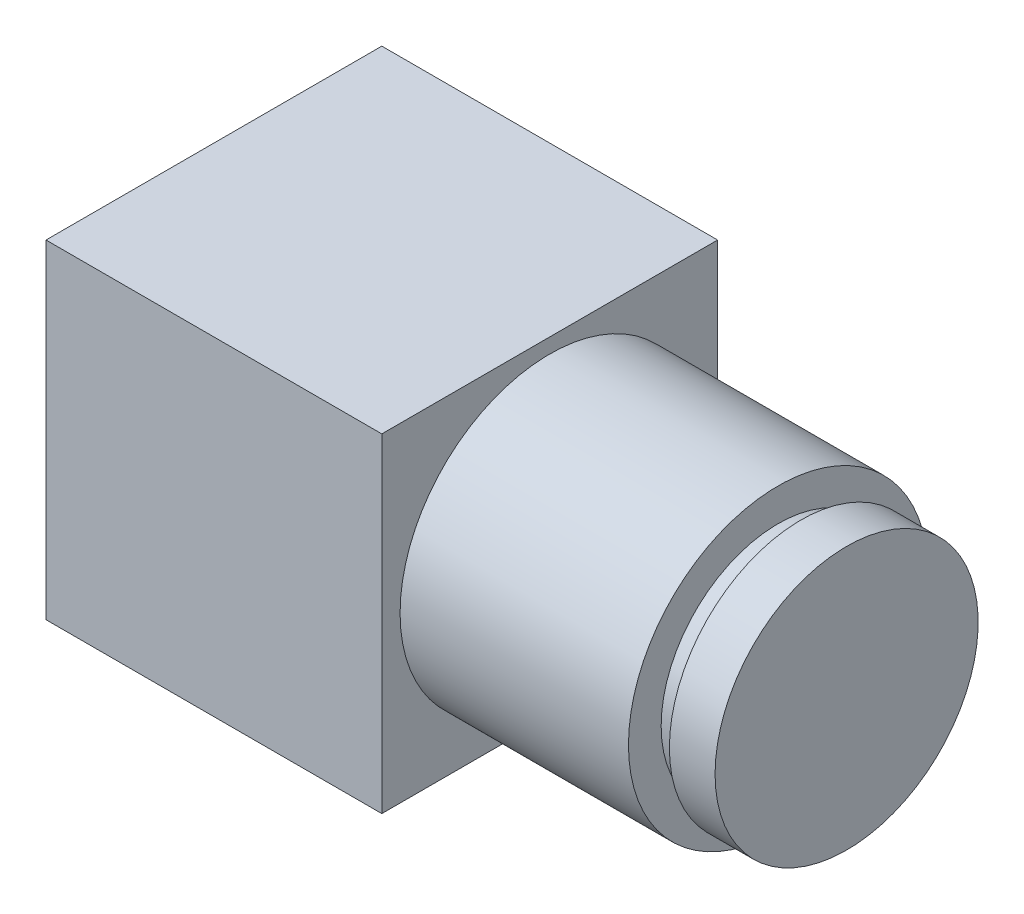
from build123d import *

# Parameters (mm, degrees)
SKETCH1_W           = 11.6713
SKETCH1_H           = 11.43
EXTRUDE1_DEPTH      = 5.83565
EXTRUDE1_DEPTH_BACK = 5.83565
SKETCH2_R           = 5.20065
EXTRUDE2_DEPTH      = 7.9375


with BuildPart() as part:
    # Sketch1 → Extrude1 (new body, two sides)
    with BuildSketch(Plane.XY) as extrude1_sk:
        with Locations((5.83565, 0)):
            Rectangle(SKETCH1_W, SKETCH1_H)
    extrude(amount=EXTRUDE1_DEPTH)
    extrude(extrude1_sk.sketch, amount=-EXTRUDE1_DEPTH_BACK)

    # Sketch2 → Extrude2 (add)
    with BuildSketch(Plane(origin=(11.6713, 0, 0), x_dir=(0, 0, -1), z_dir=(1, 0, 0))):
        Circle(SKETCH2_R)
    extrude(amount=EXTRUDE2_DEPTH)

    # Sketch3 → Revolve1 (revolve)
    with BuildSketch(Plane.XY):
        Polygon((19.6088, 0), (19.6088, 4.064), (20.40255, 4.064), (20.40255, 4.572), (21.99005, 4.572), (21.99005, 0), align=None)
    revolve(axis=Axis((0, 0, 0), (1, 0, 0)))


solid = part.part
